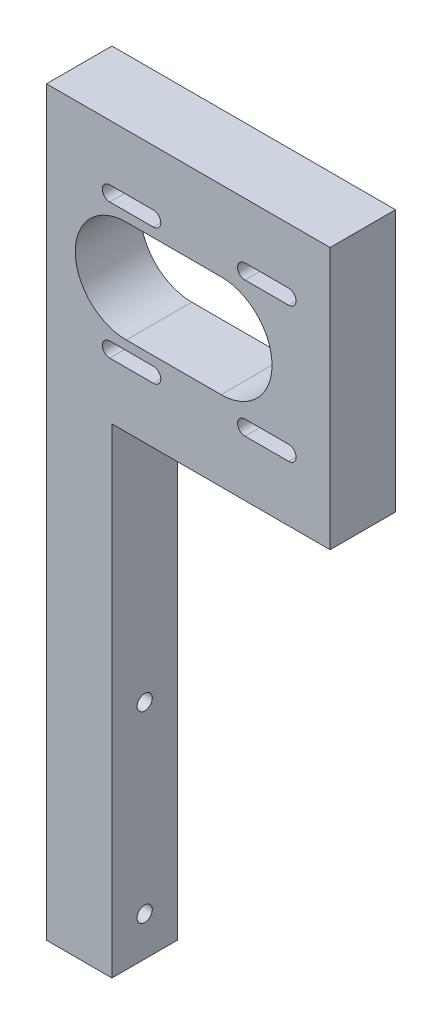
from build123d import *

# Parameters (mm, degrees)
SKETCH1_W           = 15
SKETCH1_H           = 15
BOSS_EXTRUDE1_DEPTH = 170
SKETCH2_R           = 1.75
CUT_EXTRUDE1_DEPTH  = 16
SKETCH8_W           = 15
SKETCH8_H           = 60
BOSS_EXTRUDE2_DEPTH = 50
SKETCH9_W           = 15
SKETCH9_H           = 22
CUT_EXTRUDE2_DEPTH  = 31
SKETCH11_R          = 4.05
CUT_EXTRUDE3_DEPTH  = 10
SKETCH12_W          = 15
SKETCH12_H          = 22
BOSS_EXTRUDE3_DEPTH = 31
CUT_EXTRUDE4_DEPTH  = 16


with BuildPart() as part:
    # Sketch1 → Boss-Extrude1 (new body)
    with BuildSketch(Plane(origin=(0, 0, 0), x_dir=(1, 0, 0), z_dir=(0, 1, 0))):
        Rectangle(SKETCH1_W, SKETCH1_H)
    extrude(amount=BOSS_EXTRUDE1_DEPTH)

    # Sketch2 → Cut-Extrude1 (cut, through all)
    with BuildSketch(Plane(origin=(7.5, 0, 0), x_dir=(0, 0, -1), z_dir=(1, 0, 0))):
        with Locations((0, 9)):
            Circle(SKETCH2_R)
        with Locations((0, 51)):
            Circle(SKETCH2_R)
    extrude(amount=-CUT_EXTRUDE1_DEPTH, mode=Mode.SUBTRACT)

    # Sketch8 → Boss-Extrude2 (add)
    with BuildSketch(Plane(origin=(7.5, 0, 0), x_dir=(0, 0, -1), z_dir=(1, 0, 0))):
        with Locations((0, 140)):
            Rectangle(SKETCH8_W, SKETCH8_H)
    extrude(amount=BOSS_EXTRUDE2_DEPTH)

    # Sketch9 → Cut-Extrude2 (cut)
    with BuildSketch(Plane(origin=(57.5, 0, 0), x_dir=(0, 0, -1), z_dir=(1, 0, 0))):
        with Locations((0, 150)):
            Rectangle(SKETCH9_W, SKETCH9_H)
    extrude(amount=-CUT_EXTRUDE2_DEPTH, mode=Mode.SUBTRACT)

    # Sketch11 → Cut-Extrude3 (cut)
    with BuildSketch(Plane.ZY.offset(7.5)):
        with Locations((0, 161)):
            Circle(SKETCH11_R)
        with Locations((0, 119)):
            Circle(SKETCH11_R)
    extrude(amount=-CUT_EXTRUDE3_DEPTH, mode=Mode.SUBTRACT)

    # Sketch12 → Boss-Extrude3 (add)
    with BuildSketch(Plane(origin=(26.5, 0, 0), x_dir=(0, 0, -1), z_dir=(1, 0, 0))):
        with Locations((0, 150)):
            Rectangle(SKETCH12_W, SKETCH12_H)
    extrude(amount=BOSS_EXTRUDE3_DEPTH)

    # Sketch13 → Cut-Extrude4 (cut, through all)
    with BuildSketch(Plane.XY.offset(7.5)):
        with BuildLine():
            Line((17, 122.8), (7, 122.8))
            ThreePointArc((7, 122.8), (5.3, 124.5), (7, 126.2))
            Line((7, 126.2), (17, 126.2))
            ThreePointArc((17, 126.2), (18.7, 124.5), (17, 122.8))
        make_face()
        with BuildLine():
            Line((32.5, 128.3), (10.8, 128.3))
            ThreePointArc((10.8, 128.3), (-0.9, 140), (10.8, 151.7))
            Line((10.8, 151.7), (32.5, 151.7))
            ThreePointArc((32.5, 151.7), (44.2, 140), (32.5, 128.3))
        make_face()
        with BuildLine():
            Line((48, 122.8), (38, 122.8))
            ThreePointArc((38, 122.8), (36.3, 124.5), (38, 126.2))
            Line((38, 126.2), (48, 126.2))
            ThreePointArc((48, 126.2), (49.7, 124.5), (48, 122.8))
        make_face()
        with BuildLine():
            Line((48, 153.8), (38, 153.8))
            ThreePointArc((38, 153.8), (36.3, 155.5), (38, 157.2))
            Line((38, 157.2), (48, 157.2))
            ThreePointArc((48, 157.2), (49.7, 155.5), (48, 153.8))
        make_face()
        with BuildLine():
            Line((17, 153.8), (7, 153.8))
            ThreePointArc((7, 153.8), (5.3, 155.5), (7, 157.2))
            Line((7, 157.2), (17, 157.2))
            ThreePointArc((17, 157.2), (18.7, 155.5), (17, 153.8))
        make_face()
    extrude(amount=-CUT_EXTRUDE4_DEPTH, mode=Mode.SUBTRACT)


solid = part.part
